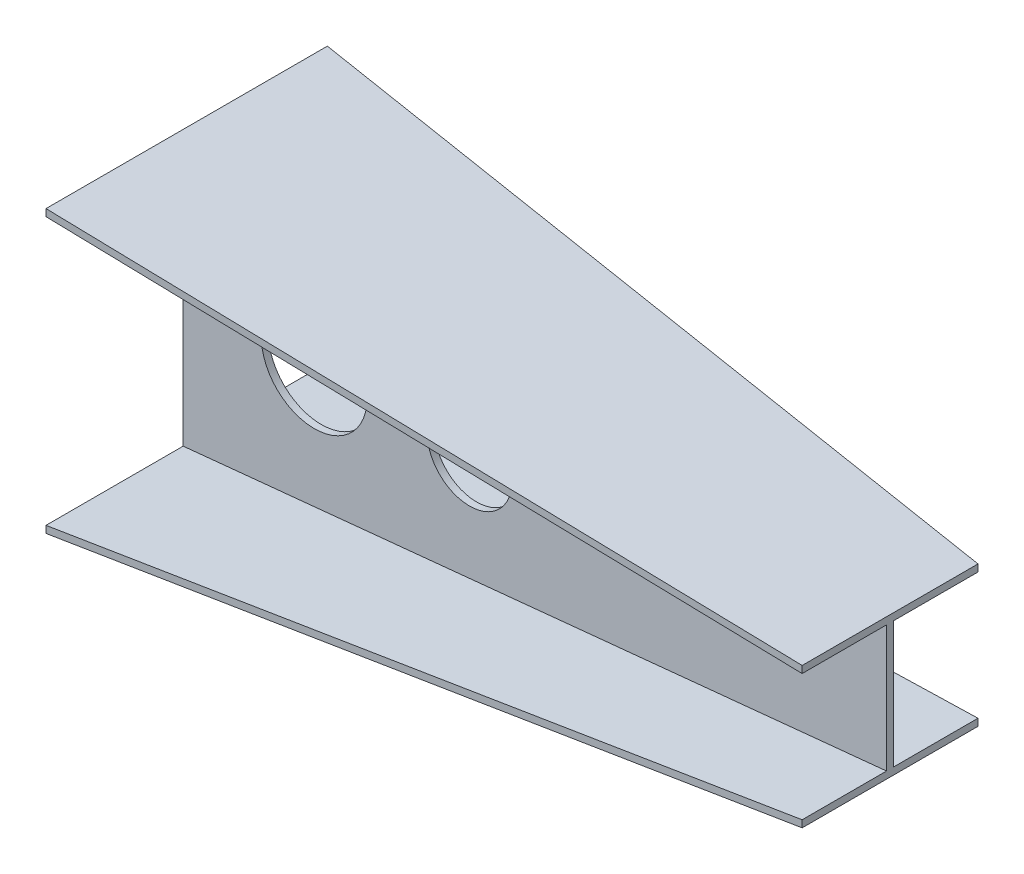
from build123d import *

# Parameters (mm, degrees)
SKETCH5_R          = 75.245114963
SKETCH5_R_2        = 60.176466442
CUT_EXTRUDE1_DEPTH = 10


with BuildPart() as part:
    # Sketch1 → Loft4 section 0
    with BuildSketch(Plane(origin=(0, 0, 0), x_dir=(0, 0, -1), z_dir=(1, 0, 0))):
        Polygon((-205, 200), (195, 200), (195, 190), (0, 190), (0, -190), (195, -190), (195, -200), (-205, -200), (-205, -190), (-10, -190), (-10, 190), (-205, 190), align=None)
    # Sketch4 → Loft4 section 1
    with BuildSketch(Plane(origin=(1000, 0, -1000), x_dir=(0, 0, 1), z_dir=(-1, 0, 0))):
        Polygon((880, 100), (1130, 100), (1130, 90), (1010, 90), (1010, -90), (1130, -90), (1130, -100), (880, -100), (880, -90), (1000, -90), (1000, 90), (880, 90), align=None)
    loft()

    # Sketch5 → Cut-Extrude1 (cut)
    with BuildSketch(Plane.XY.offset(10)):
        with Locations((186.377200583, 0)):
            Circle(SKETCH5_R)
        with Locations((407.046905619, 0)):
            Circle(SKETCH5_R_2)
    extrude(amount=-CUT_EXTRUDE1_DEPTH, mode=Mode.SUBTRACT)


solid = part.part
